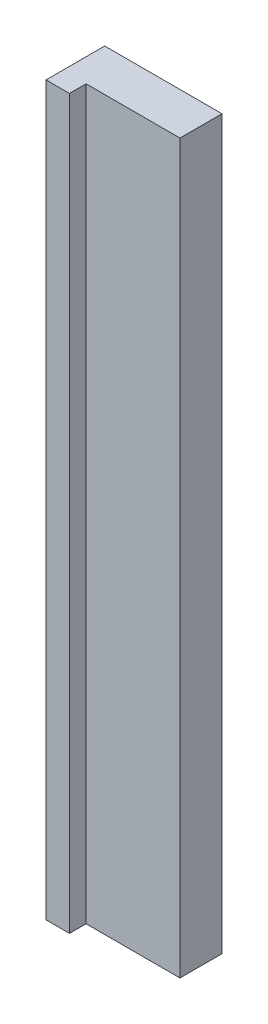
from build123d import *

# Parameters (mm, degrees)
ESQUISSE1_W        = 60
ESQUISSE1_H        = 372
BOSS_EXTRU_1_DEPTH = 21.5
ESQUISSE2_W        = 12
ESQUISSE2_H        = 372
BOSS_EXTRU_2_DEPTH = 8.5


with BuildPart() as part:
    # Esquisse1 → Boss.-Extru.1 (new body)
    with BuildSketch(Plane.XY):
        with Locations((7, -45)):
            Rectangle(ESQUISSE1_W, ESQUISSE1_H)
    extrude(amount=BOSS_EXTRU_1_DEPTH)

    # Esquisse2 → Boss.-Extru.2 (add)
    with BuildSketch(Plane.XY.offset(21.5)):
        with Locations((-17, -45)):
            Rectangle(ESQUISSE2_W, ESQUISSE2_H)
    extrude(amount=BOSS_EXTRU_2_DEPTH)


solid = part.part
